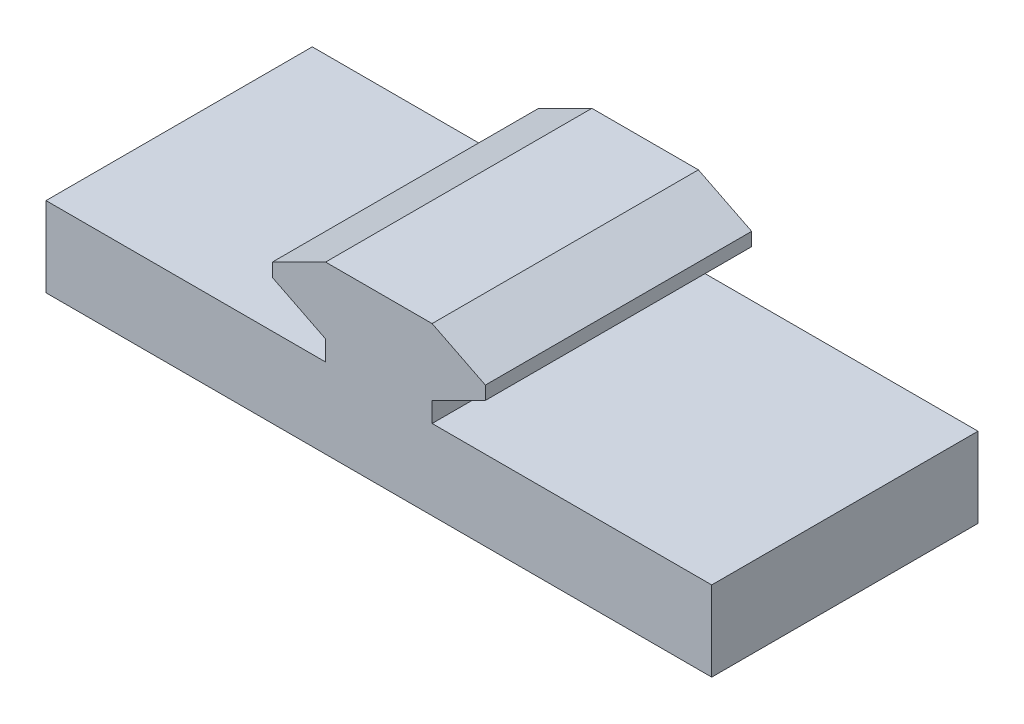
from build123d import *

# Parameters (mm, degrees)
EXTRUDE_1_DEPTH = 20


with BuildPart() as part:
    # Эскиз1 → Бобышка-Вытянуть1 (new body)
    with BuildSketch(Plane.XY):
        Polygon((-9.845304567, -8.192930284), (40.154695433, -8.192930284), (40.154695433, -2.192930284), (19.154695433, -2.192930284), (19.154695433, -0.692930284), (23.154695433, 1.307069716), (23.154695433, 2.307069716), (19.154695433, 4.307069716), (11.154695433, 4.307069716), (7.154695433, 2.307069716), (7.154695433, 1.307069716), (11.154695433, -0.692930284), (11.154695433, -2.192930284), (-9.845304567, -2.192930284), align=None)
    extrude(amount=EXTRUDE_1_DEPTH)


solid = part.part
